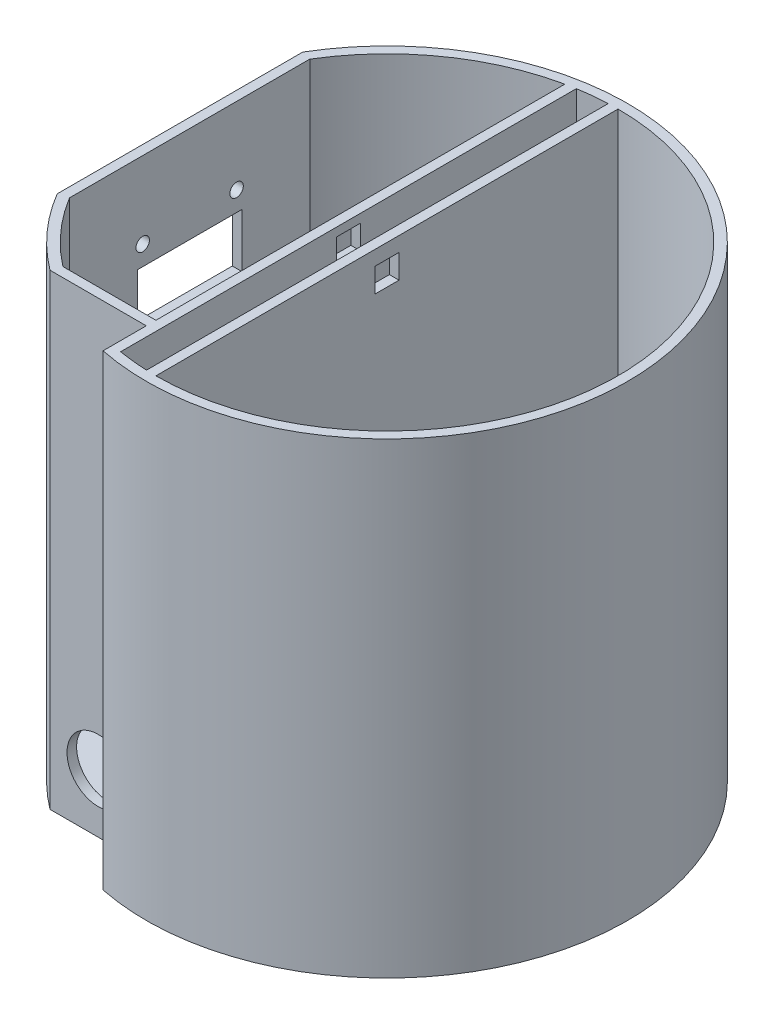
from build123d import *

# Parameters (mm, degrees)
BOSS_EXTRUDE1_DEPTH = 3
BOSS_EXTRUDE2_DEPTH = 94
SKETCH4_R           = 1.4
SKETCH4_R_2         = 1.25
CUT_EXTRUDE1_DEPTH  = 2
SKETCH5_R           = 6.5
CUT_EXTRUDE2_DEPTH  = 2
SKETCH6_R           = 1
SKETCH6_R_2         = 1.25
CUT_EXTRUDE3_DEPTH  = 2
CUT_EXTRUDE4_DEPTH  = 2


with BuildPart() as part:
    # Sketch2 → Boss-Extrude1 (new body)
    with BuildSketch(Plane(origin=(0, 0, 0), x_dir=(1, 0, 0), z_dir=(0, 1, 0))):
        with BuildLine():
            Line((-43, 25.514701644), (-43, -25.514701644))
            ThreePointArc((-43, -25.514701644), (-37.211637523, -33.396018219), (-30, -40))
            Line((-30, -40), (-10, -40))
            Line((-10, -40), (-10, -48.989794856))
            ThreePointArc((-10, -48.989794856), (45.716299059, 20.248950598), (-43, 25.514701644))
        make_face()
    extrude(amount=BOSS_EXTRUDE1_DEPTH)

    # Sketch3 → Boss-Extrude2 (add)
    with BuildSketch(Plane(origin=(0, 3, 0), x_dir=(1, 0, 0), z_dir=(0, 1, 0))):
        with BuildLine():
            Line((-43, 25.514701644), (-43, -25.514701644))
            ThreePointArc((-43, -25.514701644), (-37.211637523, -33.396018219), (-30, -40))
            Line((-30, -40), (-10, -40))
            Line((-10, -40), (-10, -48.989794856))
            ThreePointArc((-10, -48.989794856), (45.716299059, 20.248950598), (-43, 25.514701644))
        make_face()
        with BuildLine():
            Line((-41, 24.959967949), (-41, -24.959967949))
            ThreePointArc((-41, -24.959967949), (-35.762251316, -32.01657978), (-29.325756597, -38))
            Line((-29.325756597, -38), (-10, -38))
            Line((-10, -38), (-10, 46.946778377))
            ThreePointArc((-10, 46.946778377), (-27.768776678, 39.152203537), (-41, 24.959967949))
        make_face(mode=Mode.SUBTRACT)
        with BuildLine():
            Line((-8, -38), (-8, -47.328638265))
            ThreePointArc((-8, -47.328638265), (-5.009902521, -47.737834856), (-2, -47.958315233))
            Line((-2, -47.958315233), (-2, 47.958315233))
            ThreePointArc((-2, 47.958315233), (-5.009902521, 47.737834856), (-8, 47.328638265))
            Line((-8, 47.328638265), (-8, -38))
        make_face(mode=Mode.SUBTRACT)
        with BuildLine():
            Line((0, 0), (0, 48))
            ThreePointArc((0, 48), (48, 0), (0, -48))
            Line((0, -48), (0, 0))
        make_face(mode=Mode.SUBTRACT)
    extrude(amount=BOSS_EXTRUDE2_DEPTH)

    # Sketch4 → Cut-Extrude1 (cut)
    with BuildSketch(Plane.ZY.offset(43)):
        with Locations((-9.75, 81.085264892)):
            Circle(SKETCH4_R)
        with Locations((9.75, 81.085264892)):
            Circle(SKETCH4_R)
        with Locations((0, 40.068908633)):
            Circle(SKETCH4_R_2)
        Polygon((0, 65.82), (10.87, 65.82), (10.87, 77), (-10.87, 77), (-10.87, 65.82), align=None)
        Polygon((-7.5, 55.590703336), (7.5, 55.590703336), (7.5, 51.590703336), (0, 51.590703336), (-7.5, 51.590703336), align=None)
        Polygon((0, 35.068908633), (6, 35.068908633), (6, 19.568908633), (-6, 19.568908633), (-6, 35.068908633), align=None)
    extrude(amount=-CUT_EXTRUDE1_DEPTH, mode=Mode.SUBTRACT)

    # Sketch5 → Cut-Extrude2 (cut)
    with BuildSketch(Plane.XY.offset(40)):
        with Locations((-19.974192729, 12)):
            Circle(SKETCH5_R)
    extrude(amount=-CUT_EXTRUDE2_DEPTH, mode=Mode.SUBTRACT)

    # Sketch6 → Cut-Extrude3 (cut)
    with BuildSketch(Plane.ZY.offset(10)):
        with Locations((-27.5, 82)):
            Circle(SKETCH6_R)
        with Locations((27.5, 82)):
            Circle(SKETCH6_R)
        with Locations((27.5, 9)):
            Circle(SKETCH6_R)
        with Locations((-27.5, 9)):
            Circle(SKETCH6_R)
        with Locations((-15, 88.839838551)):
            Circle(SKETCH6_R_2)
        with Locations((15, 88.839838551)):
            Circle(SKETCH6_R_2)
        with Locations((15, 58.839838551)):
            Circle(SKETCH6_R_2)
        with Locations((-15, 58.839838551)):
            Circle(SKETCH6_R_2)
        Polygon((-2.5, 95.222950519), (0, 95.222950519), (2.5, 95.222950519), (2.5, 90.222950519), (-2.5, 90.222950519), align=None)
    extrude(amount=-CUT_EXTRUDE3_DEPTH, mode=Mode.SUBTRACT)

    # Sketch7 → Cut-Extrude4 (cut)
    with BuildSketch(Plane.ZY.offset(2)):
        Polygon((-2.5, 93.960891169), (0, 93.960891169), (2.5, 93.960891169), (2.5, 88.960891169), (-2.5, 88.960891169), align=None)
    extrude(amount=-CUT_EXTRUDE4_DEPTH, mode=Mode.SUBTRACT)


solid = part.part
